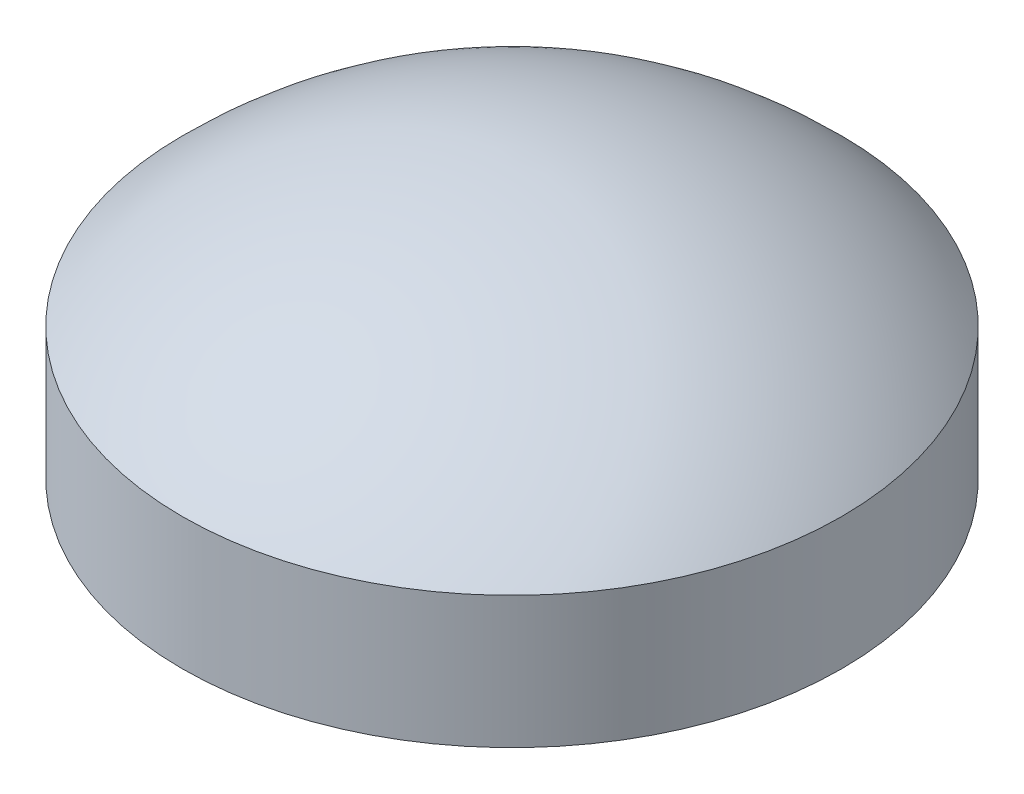
from build123d import *


with BuildPart() as part:
    # Sketch1 → Revolve1 (revolve)
    with BuildSketch(Plane.XY):
        with BuildLine():
            Line((-100, -42.020410289), (-100, -82.020410289))
            Line((-100, -82.020410289), (-97, -82.020410289))
            Line((-97, -82.020410289), (-97, -43.25290702))
            ThreePointArc((-97, -43.25290702), (-52.510228822, -13.462749085), (0, -3))
            Line((0, -3), (0, 0))
            ThreePointArc((0, 0), (-54.234940031, -10.931912233), (-100, -42.020410289))
        make_face()
    revolve(axis=Axis((0, 0, 0), (0, -1, 0)))


solid = part.part
